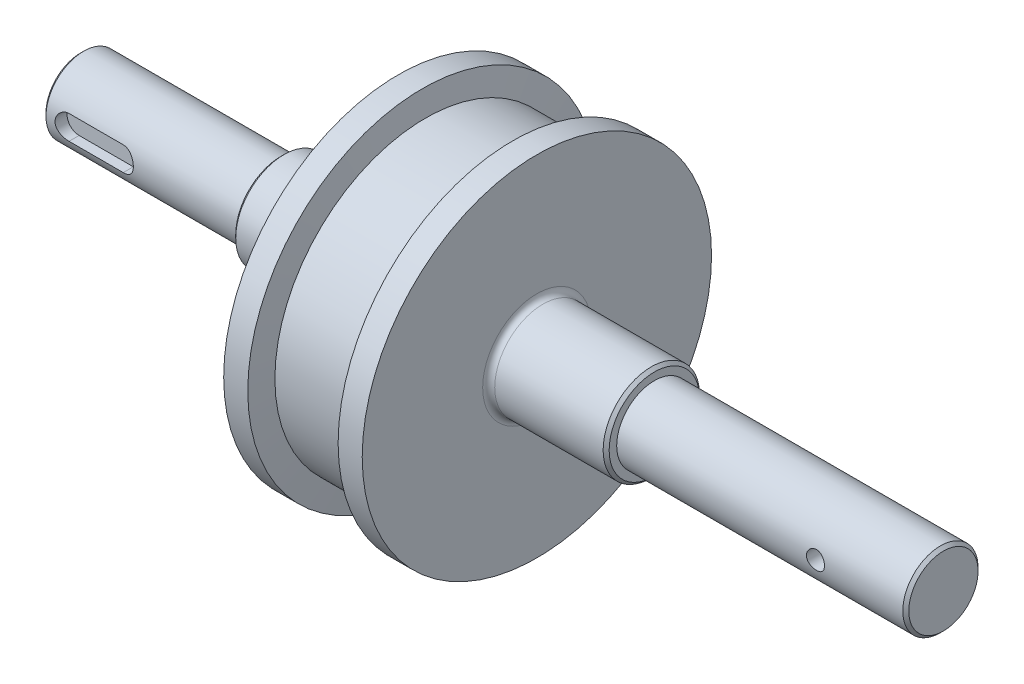
from build123d import *

# Parameters (mm, degrees)
SKETCH_2_R          = 3
CUT_EXTRUDE_1_DEPTH = 15
CUT_EXTRUDE_2_DEPTH = 4


with BuildPart() as part:
    # 草图1 → 旋转1 (revolve)
    with BuildSketch(Plane.XY):
        with BuildLine():
            Line((67.5, 16), (103.5, 16))
            ThreePointArc((103.5, 16), (104.914213562, 16.585786438), (105.5, 18))
            Line((105.5, 18), (105.5, 58))
            Line((105.5, 58), (113.5, 58))
            Line((113.5, 58), (114.5, 50))
            Line((114.5, 50), (142.5, 50))
            Line((142.5, 50), (143.5, 58))
            Line((143.5, 58), (151.5, 58))
            Line((151.5, 58), (151.5, 18))
            ThreePointArc((151.5, 18), (152.085786438, 16.585786438), (153.5, 16))
            Line((153.5, 16), (189.5, 16))
            Line((189.5, 16), (190.5, 15))
            Line((190.5, 15), (190.5, 12.5))
            Line((190.5, 12.5), (285.5, 12.5))
            Line((285.5, 12.5), (286.5, 11.5))
            Line((286.5, 11.5), (286.5, 0))
            Line((286.5, 0), (0, 0))
            Line((0, 0), (0, 11.5))
            Line((0, 11.5), (1, 12.5))
            Line((1, 12.5), (66.5, 12.5))
            Line((66.5, 12.5), (66.5, 15))
            Line((66.5, 15), (67.5, 16))
        make_face()
    revolve(axis=Axis((0, 0, 0), (1, 0, 0)))

    # 草图2 → 切除-拉伸1 (cut, symmetric)
    with BuildSketch(Plane.XY):
        with Locations((256.5, 0)):
            Circle(SKETCH_2_R)
    extrude(amount=CUT_EXTRUDE_1_DEPTH, both=True, mode=Mode.SUBTRACT)

    # 草图3 → 切除-拉伸2 (cut)
    with BuildSketch(Plane.XY.offset(12.5)):
        with BuildLine():
            Line((8, 4), (26, 4))
            ThreePointArc((26, 4), (30, 0), (26, -4))
            Line((26, -4), (8, -4))
            ThreePointArc((8, -4), (4, 0), (8, 4))
        make_face()
    extrude(amount=-CUT_EXTRUDE_2_DEPTH, mode=Mode.SUBTRACT)


solid = part.part
